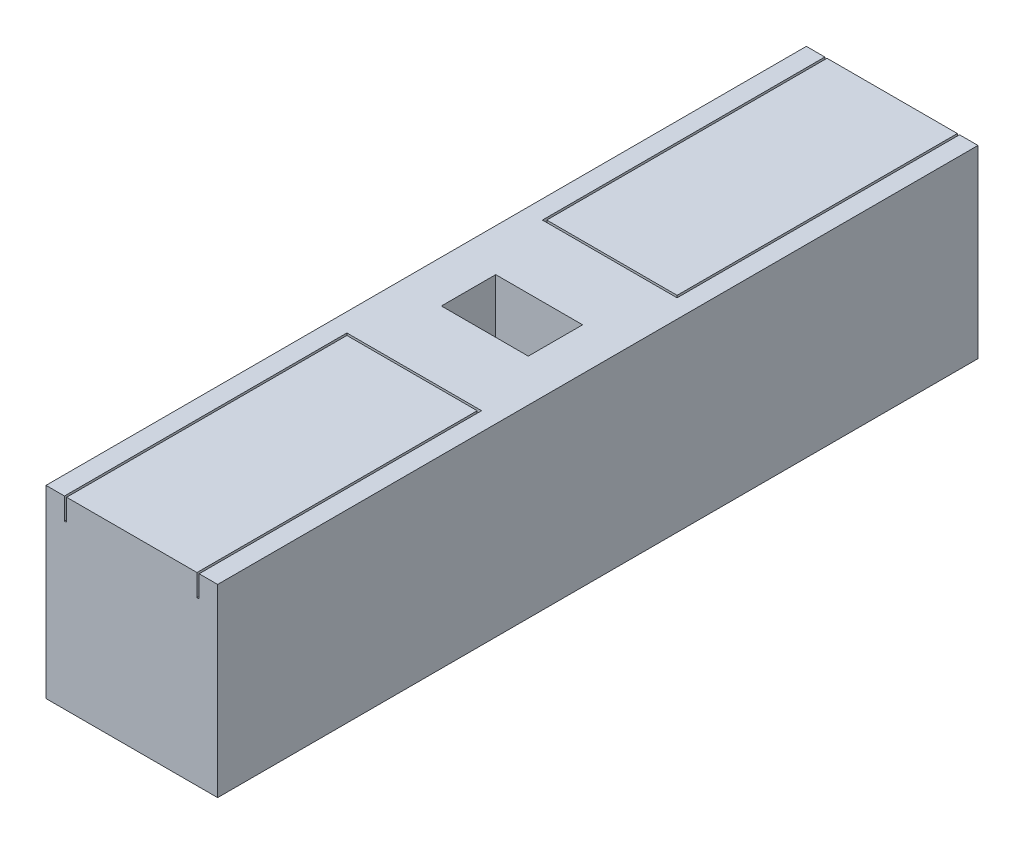
from build123d import *

# Parameters (mm, degrees)
SKETCH1_W           = 7.9
SKETCH1_H           = 8.5
BOSS_EXTRUDE1_DEPTH = 35
CUT_EXTRUDE1_DEPTH  = 1
SKETCH3_W           = 4
SKETCH3_H           = 2.5
CUT_EXTRUDE2_DEPTH  = 3.5


with BuildPart() as part:
    # Sketch1 → Boss-Extrude1 (new body)
    with BuildSketch(Plane.XY):
        with Locations((3.95, 4.25)):
            Rectangle(SKETCH1_W, SKETCH1_H)
    extrude(amount=BOSS_EXTRUDE1_DEPTH)

    # Sketch2 → Cut-Extrude1 (cut)
    with BuildSketch(Plane(origin=(0, 8.5, 0), x_dir=(1, 0, 0), z_dir=(0, 1, 0))):
        Polygon((0.85, -35), (0.95, -35), (0.95, -22.1), (6.95, -22.1), (6.95, -35), (7.05, -35), (7.05, -22), (0.85, -22), align=None)
        Polygon((6.95, 0), (7.05, 0), (7.05, -13), (0.85, -13), (0.85, 0), (0.95, 0), (0.95, -12.9), (6.95, -12.9), align=None)
    extrude(amount=-CUT_EXTRUDE1_DEPTH, mode=Mode.SUBTRACT)

    # Sketch3 → Cut-Extrude2 (cut)
    with BuildSketch(Plane(origin=(0, 8.5, 0), x_dir=(1, 0, 0), z_dir=(0, 1, 0))):
        with Locations((3.95, -17.5)):
            Rectangle(SKETCH3_W, SKETCH3_H)
    extrude(amount=-CUT_EXTRUDE2_DEPTH, mode=Mode.SUBTRACT)


solid = part.part
